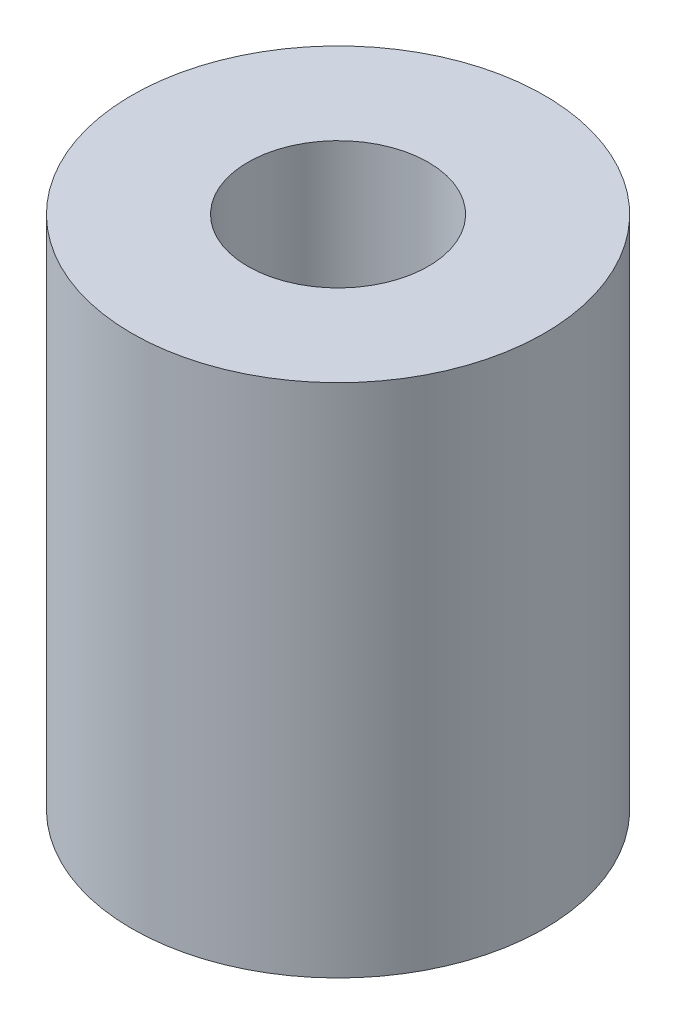
from build123d import *

# Parameters (mm, degrees)
SKETCH_1_R      = 4
SKETCH_1_R_2    = 1.75
EXTRUDE_1_DEPTH = 10


with BuildPart() as part:
    # Эскиз1 → Бобышка-Вытянуть1 (new body)
    with BuildSketch(Plane(origin=(0, 0, 0), x_dir=(1, 0, 0), z_dir=(0, 1, 0))):
        Circle(SKETCH_1_R)
        Circle(SKETCH_1_R_2, mode=Mode.SUBTRACT)
    extrude(amount=EXTRUDE_1_DEPTH)


solid = part.part
